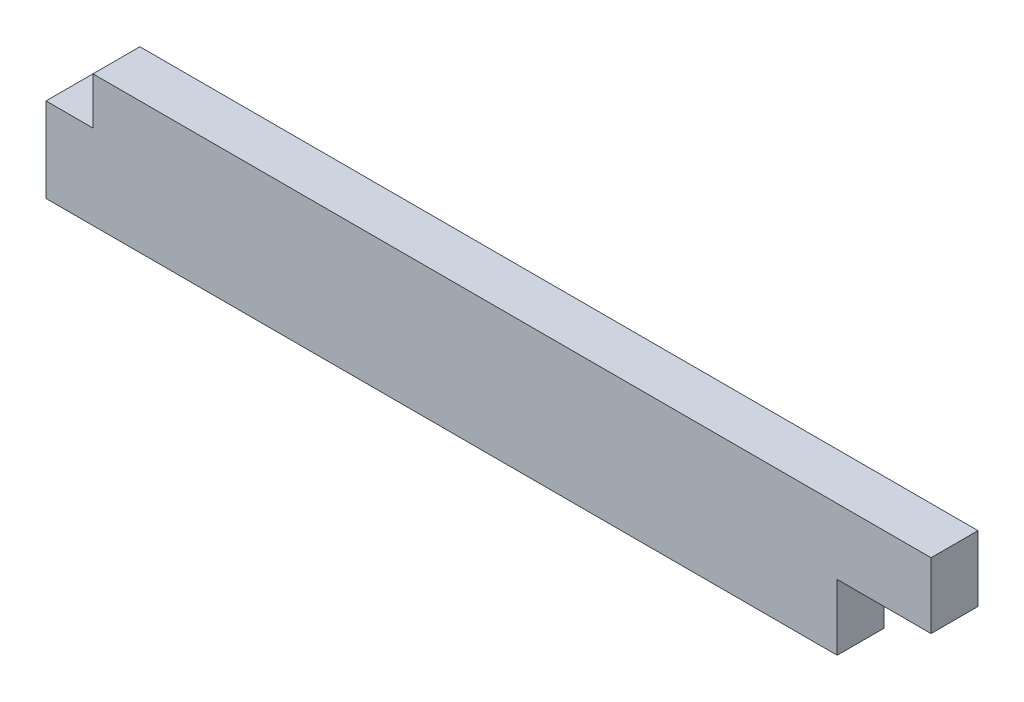
from build123d import *

# Parameters (mm, degrees)
EXTRUDE_1_DEPTH = 1.4


with BuildPart() as part:
    # Эскиз1 → Бобышка-Вытянуть1 (new, symmetric)
    with BuildSketch(Plane.XY):
        Polygon((-31.142857143, -2.8), (13.257142857, -2.8), (13.257142857, 1.12), (18.857142857, 1.12), (18.857142857, 5.04), (-31.142857143, 5.04), (-31.142857143, 2.24), (-33.942857143, 2.24), (-33.942857143, 0), (-33.942857143, -2.8), align=None)
    extrude(amount=EXTRUDE_1_DEPTH, both=True)


solid = part.part
